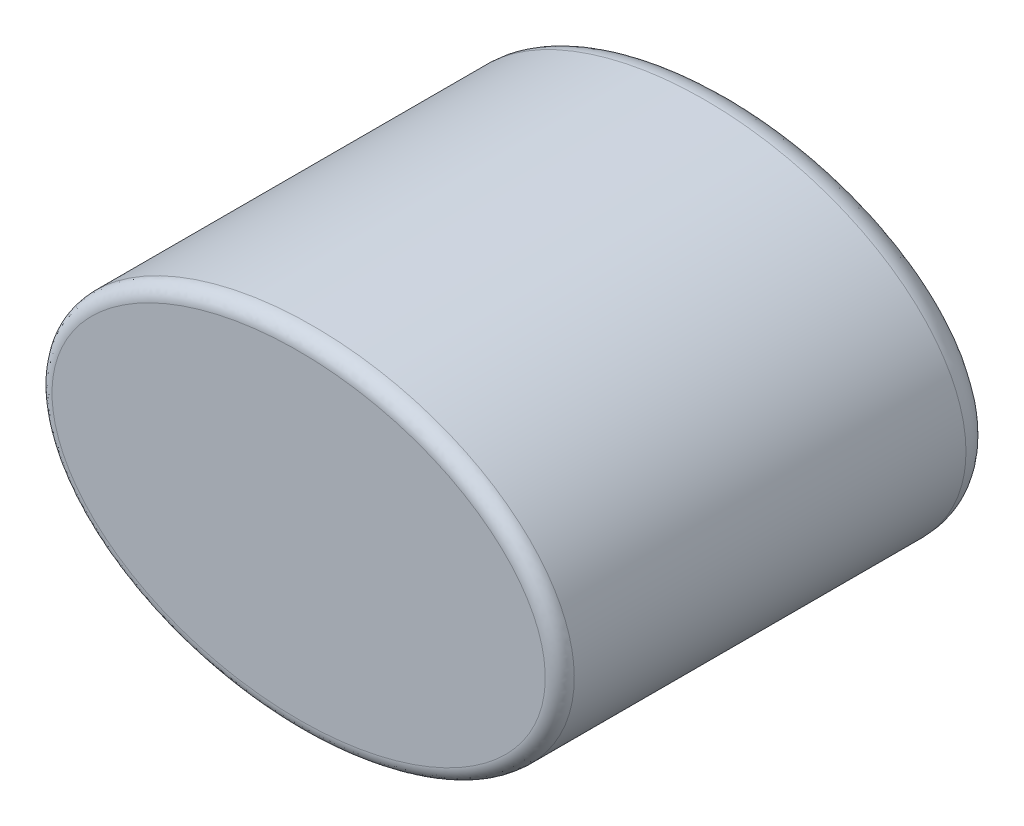
from build123d import *

# Parameters (mm, degrees)
SKETCH1_RX              = 22.86
SKETCH1_RY              = 15.24
BOSS_EXTRUDE4_DEPTH     = 45.72
CUT_EXTRUDE2_START      = -10.16
SKETCH4_W               = 29.21
SKETCH4_H               = 17.78
CUT_EXTRUDE2_DEPTH      = 33.02
SKETCH7_W               = 14.643913221
SKETCH7_H               = 35.56
CUT_EXTRUDE4_DEPTH      = 33.02
CUT_EXTRUDE4_DEPTH_BACK = 33.02
SKETCH8_R               = 1.75
CUT_EXTRUDE5_DEPTH      = 1.27
SKETCH9_R               = 0.5
CUT_EXTRUDE7_DEPTH      = 2.794
FILLET1_R               = 2.54
FILLET2_R               = 1.27


with BuildPart() as part:
    # Sketch1 → Boss-Extrude4 (new body)
    with BuildSketch(Plane.XY):
        with Locations(Location((0, 0), (0, 0, 180))):
            Ellipse(SKETCH1_RX, SKETCH1_RY)
    extrude(amount=BOSS_EXTRUDE4_DEPTH)

    # Sketch4 → Cut-Extrude2 (cut)
    with BuildSketch(Plane.XY.offset(45.72).offset(CUT_EXTRUDE2_START)):
        Rectangle(SKETCH4_W, SKETCH4_H)
    extrude(amount=-CUT_EXTRUDE2_DEPTH, mode=Mode.SUBTRACT)

    # Sketch7 → Cut-Extrude4 (cut, two sides)
    with BuildSketch(Plane(origin=(0, 0, 0), x_dir=(0, 0, -1), z_dir=(1, 0, 0))) as cut_extrude4_sk:
        with Locations((-45.421956611, -1.677648267)):
            Rectangle(SKETCH7_W, SKETCH7_H)
    extrude(amount=CUT_EXTRUDE4_DEPTH, mode=Mode.SUBTRACT)
    extrude(cut_extrude4_sk.sketch, amount=-CUT_EXTRUDE4_DEPTH_BACK, mode=Mode.SUBTRACT)

    # Sketch8 → Cut-Extrude5 (cut)
    with BuildSketch(Plane.XY):
        Circle(SKETCH8_R)
        with Locations((4.064, 0)):
            Circle(SKETCH8_R)
        with Locations((-4.064, 0)):
            Circle(SKETCH8_R)
    extrude(amount=CUT_EXTRUDE5_DEPTH, mode=Mode.SUBTRACT)

    # Sketch9 → Cut-Extrude7 (cut)
    with BuildSketch(Plane(origin=(0, 0, 0), x_dir=(-1, 0, 0), z_dir=(0, 0, -1))):
        with Locations((0, 0.8)):
            Circle(SKETCH9_R)
        with Locations((0, -0.8)):
            Circle(SKETCH9_R)
        with Locations((-4.064, 0.8)):
            Circle(SKETCH9_R)
        with Locations((-4.064, -0.8)):
            Circle(SKETCH9_R)
        with Locations((4.064, 0.8)):
            Circle(SKETCH9_R)
        with Locations((4.064, -0.8)):
            Circle(SKETCH9_R)
    extrude(amount=-CUT_EXTRUDE7_DEPTH, mode=Mode.SUBTRACT)

    # Fillet1
    fillet1_edges = [part.edges().sort_by_distance(p)[0] for p in [
        (22.859987041, 0.016227247, 0),
    ]]
    fillet(fillet1_edges, radius=FILLET1_R)

    # Fillet2
    fillet2_edges = [part.edges().sort_by_distance(p)[0] for p in [
        (22.860000074, 1.7e-08, 38.1),
    ]]
    fillet(fillet2_edges, radius=FILLET2_R)


solid = part.part
